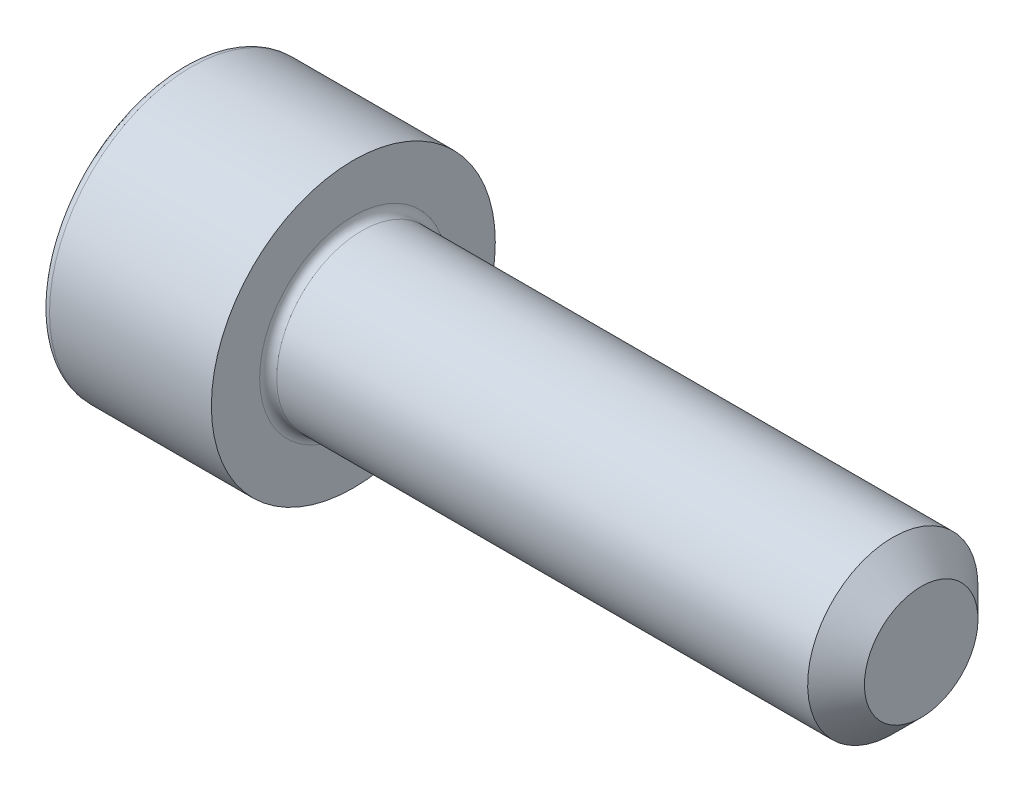
from build123d import *

# Parameters (mm, degrees)
CUT_EXTRUDE_1_DEPTH = 2.5
FILLET_1_R          = 0.3
CHAMFER_1_SIZE      = 1


with BuildPart() as part:
    # Эскиз1 → Повернуть1 (revolve)
    with BuildSketch(Plane.XY):
        Polygon((0, 0), (0, 5), (6, 5), (6, 3), (26, 3), (26, 0), align=None)
    revolve(axis=Axis((26, 0, 0), (-1, 0, 0)))

    # Эскиз2 → Вырез-Вытянуть1 (cut)
    with BuildSketch(Plane.ZY):
        Polygon((-1.443375673, 2.5), (-2.886751346, 0), (-1.443375673, -2.5), (1.443375673, -2.5), (2.886751346, 0), (1.443375673, 2.5), align=None)
    extrude(amount=-CUT_EXTRUDE_1_DEPTH, mode=Mode.SUBTRACT)

    # Скругление1
    fillet_1_edges = [part.edges().sort_by_distance(p)[0] for p in [
        (6, -3, 0),
        (0, -5, 0),
    ]]
    fillet(fillet_1_edges, radius=FILLET_1_R)

    # Фаска1
    chamfer_1_edges = [part.edges().sort_by_distance(p)[0] for p in [
        (26, -3, 0),
    ]]
    chamfer(chamfer_1_edges, length=CHAMFER_1_SIZE)


solid = part.part
